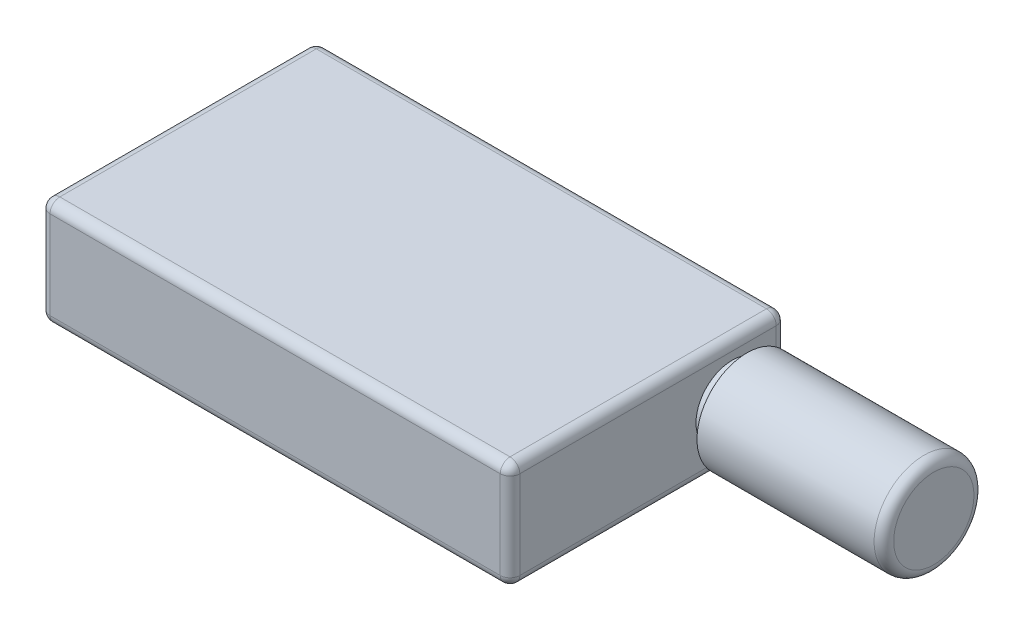
from build123d import *

# Parameters (mm, degrees)
SKETCH1_W           = 48
SKETCH1_H           = 28.2
BOSS_EXTRUDE1_DEPTH = 11
SKETCH2_R           = 3.7
BOSS_EXTRUDE2_DEPTH = 1.5
SKETCH3_R           = 5.1
BOSS_EXTRUDE3_DEPTH = 19.1
FILLET1_R           = 1
FILLET2_R           = 1
FILLET3_R           = 1


with BuildPart() as part:
    # Sketch1 → Boss-Extrude1 (new body)
    with BuildSketch(Plane(origin=(0, 0, 0), x_dir=(1, 0, 0), z_dir=(0, 1, 0))):
        with Locations((24, 14.1)):
            Rectangle(SKETCH1_W, SKETCH1_H)
    extrude(amount=BOSS_EXTRUDE1_DEPTH)

    # Sketch2 → Boss-Extrude2 (add)
    with BuildSketch(Plane(origin=(48, 0, 0), x_dir=(0, 0, -1), z_dir=(1, 0, 0))):
        with Locations((22.7, 5.5)):
            Circle(SKETCH2_R)
    extrude(amount=BOSS_EXTRUDE2_DEPTH)

    # Sketch3 → Boss-Extrude3 (add)
    with BuildSketch(Plane(origin=(49.5, 0, 0), x_dir=(0, 0, -1), z_dir=(1, 0, 0))):
        with Locations((22.7, 5.5)):
            Circle(SKETCH3_R)
    extrude(amount=BOSS_EXTRUDE3_DEPTH)

    # Fillet1
    fillet1_edges = [part.edges().sort_by_distance(p)[0] for p in [
        (48, 11, -14.1),
        (24, 11, -28.2),
        (0, 11, -14.1),
        (24, 0, -28.2),
        (48, 0, -14.1),
        (24, 0, 0),
        (0, 0, -14.1),
        (0, 5.5, -28.2),
        (48, 5.5, -28.2),
        (48, 5.5, 0),
        (0, 5.5, 0),
        (24, 11, 0),
    ]]
    fillet(fillet1_edges, radius=FILLET1_R)

    # Fillet2
    fillet2_edges = [part.edges().sort_by_distance(p)[0] for p in [
        (68.6, 5.5, -17.6),
    ]]
    fillet(fillet2_edges, radius=FILLET2_R)

    # Fillet3
    fillet3_edges = [part.edges().sort_by_distance(p)[0] for p in [
        (49.5, 5.5, -19),
    ]]
    fillet(fillet3_edges, radius=FILLET3_R)


solid = part.part
